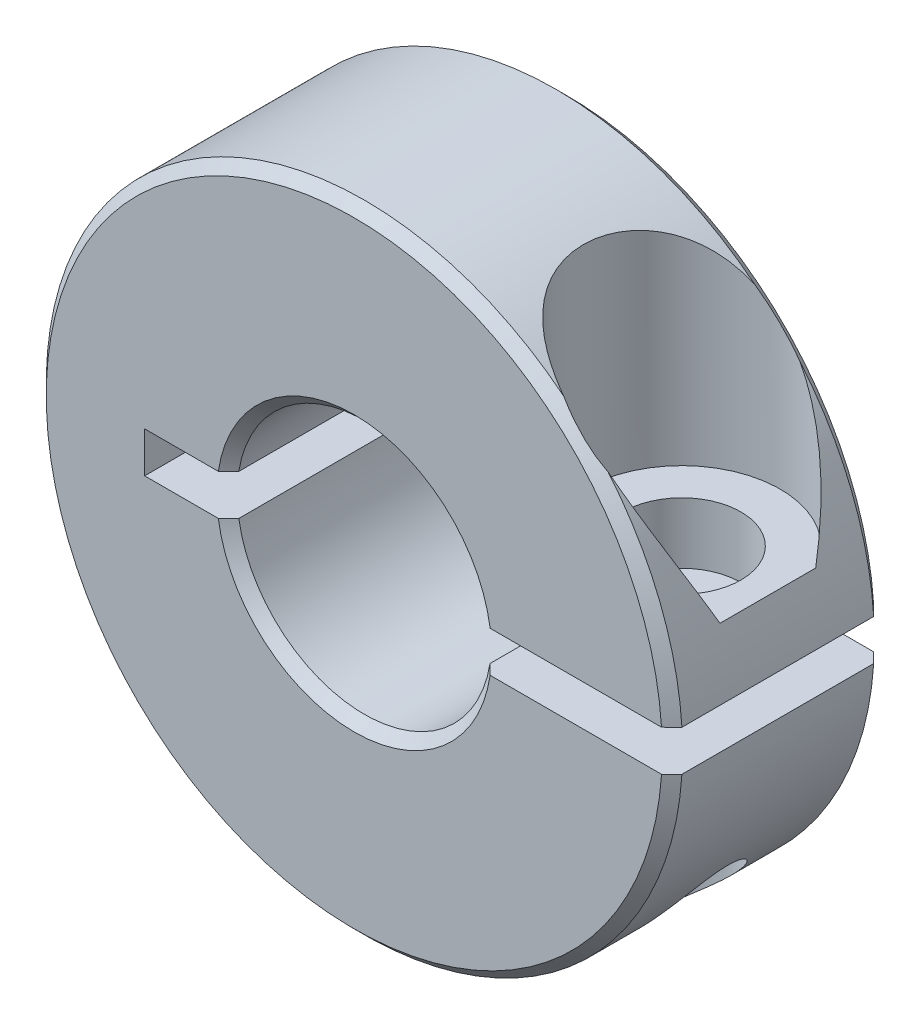
from build123d import *

# Parameters (mm, degrees)
BOSS_EXTRUDE1_DEPTH = 3.96875
SKETCH4_W           = 1.7272
SKETCH4_H           = 11.14425
CHAMFER1_SIZE       = 0.381


with BuildPart() as part:
    # Sketch1 → Boss-Extrude1 (new, symmetric)
    with BuildSketch(Plane.XY):
        with BuildLine():
            Line((-7.84225, 0.762), (-4.701144781, 0.762))
            ThreePointArc((-4.701144781, 0.762), (0, 4.7625), (4.701144781, 0.762))
            Line((4.701144781, 0.762), (11.88184098, 0.762))
            ThreePointArc((11.88184098, 0.762), (-11.90625, 0), (11.88184098, -0.762))
            Line((11.88184098, -0.762), (4.701144781, -0.762))
            ThreePointArc((4.701144781, -0.762), (0, -4.7625), (-4.701144781, -0.762))
            Line((-4.701144781, -0.762), (-7.84225, -0.762))
            Line((-7.84225, -0.762), (-7.84225, 0.762))
        make_face()
    extrude(amount=BOSS_EXTRUDE1_DEPTH, both=True)

    # Sketch4 → 8-32 Tapped Hole1 (revolve, cut)
    with BuildSketch(Plane(origin=(8.29149288, -0.762, 0), x_dir=(0, 0, 1), z_dir=(1, 0, 0))):
        with Locations((0.8636, 5.572125)):
            Rectangle(SKETCH4_W, SKETCH4_H)
    revolve(axis=Axis((8.29149288, 5.588, 0), (0, -1, 0)), mode=Mode.SUBTRACT)

    # Chamfer1
    chamfer1_edges = [part.edges().sort_by_distance(p)[0] for p in [
        (-11.90625, 0, -3.96875),
        (0, -4.7625, -3.96875),
        (0, 4.7625, -3.96875),
        (-11.90625, 0, 3.96875),
        (0, -4.7625, 3.96875),
        (0, 4.7625, 3.96875),
    ]]
    chamfer(chamfer1_edges, length=CHAMFER1_SIZE)

    # Sketch10 → Cut-Revolve1 (revolve, cut)
    with BuildSketch(Plane.XY):
        Polygon((8.29149288, 0.762), (10.50129288, 0.762), (10.50129288, 3.048), (11.97449288, 3.048), (11.97449288, 11.90625), (8.29149288, 11.90625), align=None)
    revolve(axis=Axis((8.29149288, -0.762, 0), (0, -1, 0)), mode=Mode.SUBTRACT)


solid = part.part
